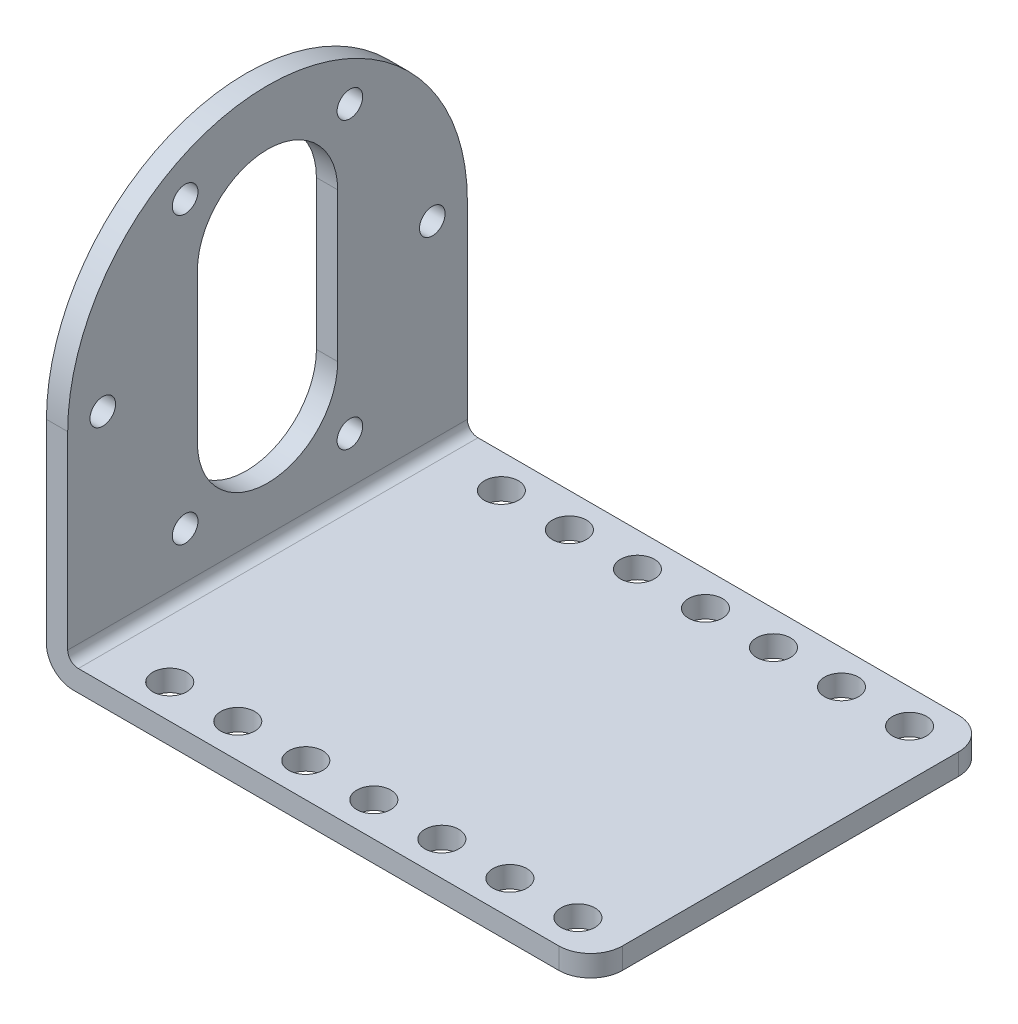
from build123d import *

# Parameters (mm, degrees)
BOSS_EXTRUDE1_DEPTH            = 18.8
CUT_EXTRUDE1_START             = -2
SKETCH2_R                      = 1.204354552
CUT_EXTRUDE1_DEPTH             = 2
FILLET1_R                      = 3
F_3_2_3_2_DIAMETER_HOLE1_D     = 3.2
F_3_2_3_2_DIAMETER_HOLE1_DEPTH = 2


with BuildPart() as part:
    # Sketch1 → Boss-Extrude1 (new body, symmetric)
    with BuildSketch(Plane.XY):
        with BuildLine():
            Line((2.5, 0), (51.2, 0))
            Line((51.2, 0), (51.2, 2))
            Line((51.2, 2), (3, 2))
            ThreePointArc((3, 2), (2.292893219, 2.292893219), (2, 3))
            Line((2, 3), (2, 39.6))
            Line((2, 39.6), (0, 39.6))
            Line((0, 39.6), (0, 2.5))
            ThreePointArc((0, 2.5), (0.732233047, 0.732233047), (2.5, 0))
        make_face()
    extrude(amount=BOSS_EXTRUDE1_DEPTH, both=True)

    # Sketch2 → Cut-Extrude1 (cut)
    with BuildSketch(Plane.ZY.offset(CUT_EXTRUDE1_START)):
        with Locations((15.5, 20.8)):
            Circle(SKETCH2_R)
        with Locations((7.75, 7.376606241)):
            Circle(SKETCH2_R)
        with Locations((-7.75, 7.376606241)):
            Circle(SKETCH2_R)
        with Locations((-15.5, 20.8)):
            Circle(SKETCH2_R)
        with Locations((-7.75, 34.223393759)):
            Circle(SKETCH2_R)
        with Locations((7.75, 34.223393759)):
            Circle(SKETCH2_R)
        with BuildLine():
            Line((6.6, 27.8), (6.6, 13.8))
            ThreePointArc((6.6, 13.8), (0, 7.2), (-6.6, 13.8))
            Line((-6.6, 13.8), (-6.6, 27.8))
            ThreePointArc((-6.6, 27.8), (0, 34.4), (6.6, 27.8))
        make_face()
        with BuildLine():
            Line((-18.8, 40.1), (-18.8, 20.8))
            ThreePointArc((-18.8, 20.8), (0, 39.6), (18.8, 20.8))
            Line((18.8, 20.8), (18.8, 40.1))
            Line((18.8, 40.1), (-18.8, 40.1))
        make_face()
    extrude(amount=CUT_EXTRUDE1_DEPTH, mode=Mode.SUBTRACT)

    # Fillet1
    fillet1_edges = [part.edges().sort_by_distance(p)[0] for p in [
        (51.2, 1, -18.8),
        (51.2, 1, 18.8),
    ]]
    fillet(fillet1_edges, radius=FILLET1_R)

    # Ø3.2 (3.2) Diameter Hole1
    with Locations(Plane(origin=(0, 2, 0), x_dir=(1, 0, 0), z_dir=(0, 1, 0))):
        with Locations((8.4, 15.6), (8.4, -15.6), (14.8, 15.6), (14.8, -15.6), (21.2, 15.6), (21.2, -15.6), (27.6, 15.6), (27.6, -15.6), (34, 15.6), (34, -15.6), (40.4, 15.6), (40.4, -15.6), (46.8, 15.6), (46.8, -15.6)):
            Hole(F_3_2_3_2_DIAMETER_HOLE1_D / 2, depth=F_3_2_3_2_DIAMETER_HOLE1_DEPTH)


solid = part.part
